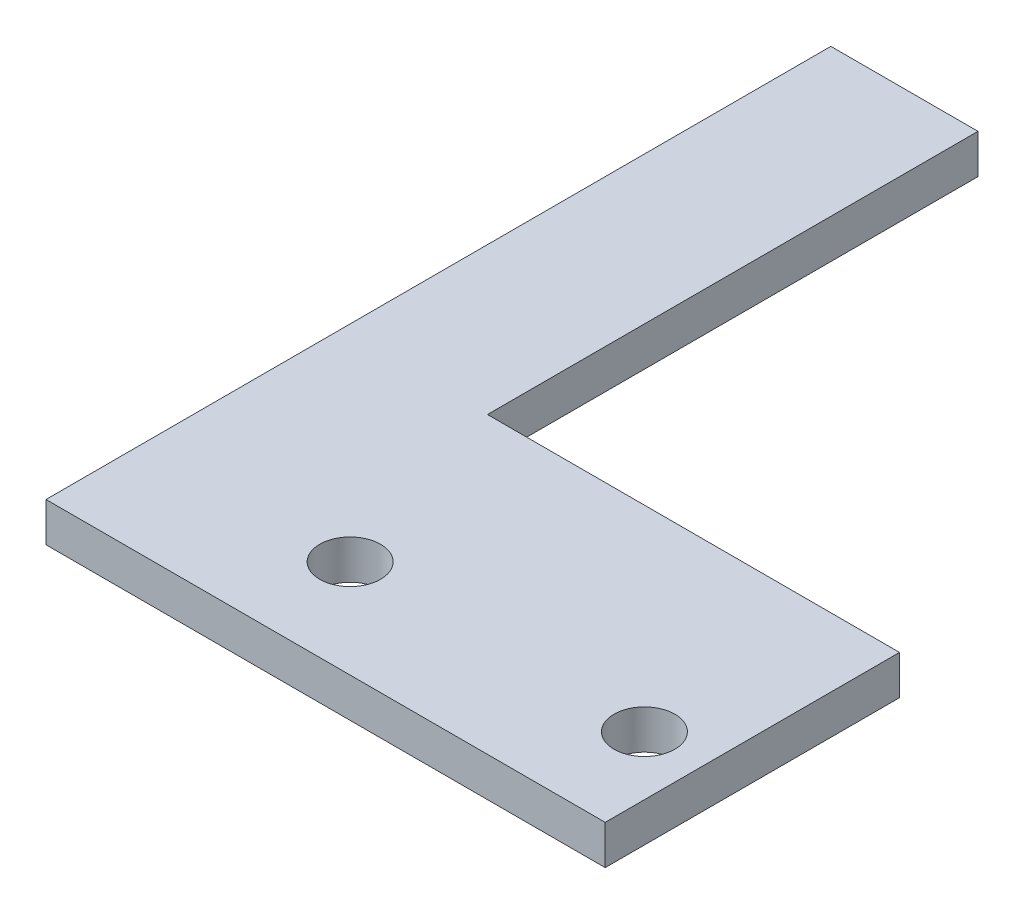
from build123d import *

# Parameters (mm, degrees)
BOSS_EXTRUDE1_DEPTH            = 2
F_3_1_3_1_DIAMETER_HOLE1_D     = 3.1
F_3_1_3_1_DIAMETER_HOLE1_DEPTH = 10
F_3_1_3_1_DIAMETER_HOLE1_TIP   = 0.931333959


with BuildPart() as part:
    # Sketch1 → Boss-Extrude1 (new body)
    with BuildSketch(Plane(origin=(0, 0, 0), x_dir=(1, 0, 0), z_dir=(0, 1, 0))):
        Polygon((0, 0), (0, 40), (7.5, 40), (7.5, 15), (28.5, 15), (28.5, 0), align=None)
    extrude(amount=BOSS_EXTRUDE1_DEPTH)

    # Ø3.1 (3.1) Diameter Hole1
    with Locations(Plane(origin=(0, 2, 0), x_dir=(1, 0, 0), z_dir=(0, 1, 0))):
        with Locations((10.5, 5), (25.5, 5)):
            Hole(F_3_1_3_1_DIAMETER_HOLE1_D / 2, depth=F_3_1_3_1_DIAMETER_HOLE1_DEPTH)
            with Locations((0, 0, -(F_3_1_3_1_DIAMETER_HOLE1_DEPTH + F_3_1_3_1_DIAMETER_HOLE1_TIP / 2))):  # 118° drill point
                Cone(0, F_3_1_3_1_DIAMETER_HOLE1_D / 2, F_3_1_3_1_DIAMETER_HOLE1_TIP, mode=Mode.SUBTRACT)


solid = part.part
